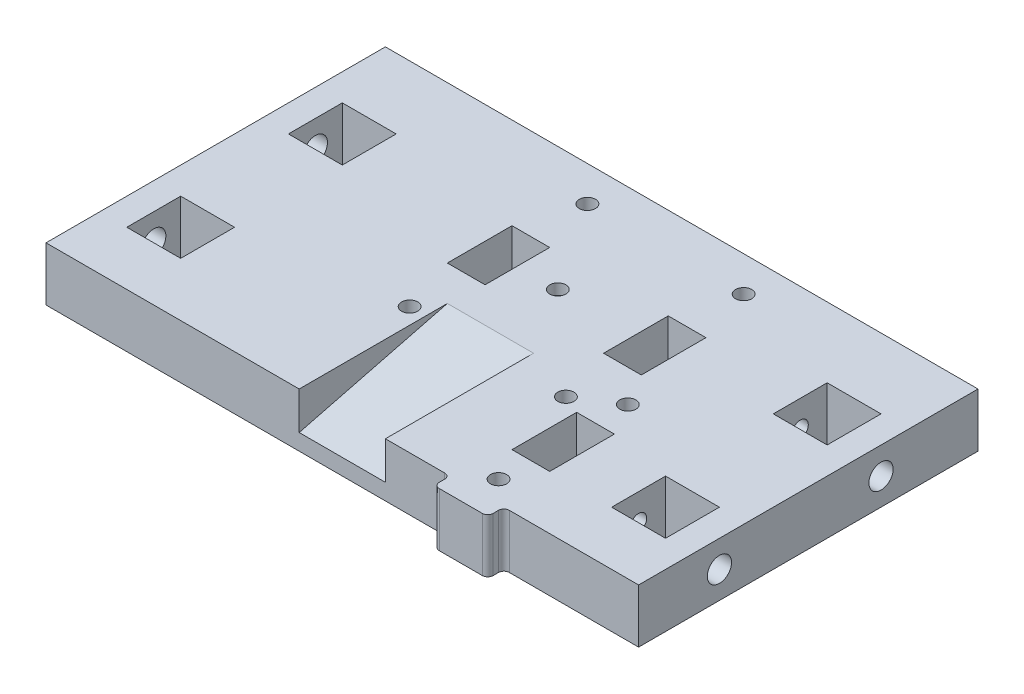
from build123d import *

# Parameters (mm, degrees)
CROQUIS1_W              = 80
CROQUIS1_H              = 60
CROQUIS1_R              = 1.5
CROQUIS1_W_2            = 7
CROQUIS1_H_2            = 25
CROQUIS1_W_3            = 10
CROQUIS1_H_3            = 20
CROQUIS1_H_4            = 10
CROQUIS1_W_4            = 5
CROQUIS1_H_5            = 6.5
SALIENTE_EXTRUIR1_DEPTH = 10
CORTAR_EXTRUIR1_DEPTH   = 5
CROQUIS3_R              = 1.5
CORTAR_EXTRUIR2_DEPTH   = 25
CROQUIS6_R              = 1.5
CORTAR_EXTRUIR3_DEPTH   = 25
CROQUIS8_W              = 15
CROQUIS8_H              = 17.838651154
CROQUIS8_R              = 1.5
SALIENTE_EXTRUIR2_DEPTH = 2
CORTAR_EXTRUIR4_START   = -55
CORTAR_EXTRUIR4_DEPTH   = 8
CROQUIS10_R             = 1.5
CROQUIS10_W             = 7
CROQUIS10_H             = 12
CORTAR_EXTRUIR5_DEPTH   = 16
CROQUIS12_W             = 110
CROQUIS12_H             = 10
SALIENTE_EXTRUIR3_DEPTH = 3
CORTAR_EXTRUIR6_DEPTH   = 5
SALIENTE_EXTRUIR4_DEPTH = 10
CROQUIS15_R             = 2.25
CORTAR_EXTRUIR7_DEPTH   = 10
CROQUIS16_R             = 2.25
CORTAR_EXTRUIR8_DEPTH   = 10


with BuildPart() as part:
    # Croquis1 → Saliente-Extruir1 (new body)
    with BuildSketch(Plane(origin=(0, 0, 0), x_dir=(1, 0, 0), z_dir=(0, 1, 0))):
        with Locations((0, -10)):
            Rectangle(CROQUIS1_W, CROQUIS1_H)
        with Locations(Location((18, -16.5, 0), (0, 0, 270))):
            Circle(CROQUIS1_R, mode=Mode.SUBTRACT)
        with Locations(Location((-11, -16.5, 0), (0, 0, 270))):
            Circle(CROQUIS1_R, mode=Mode.SUBTRACT)
        with Locations(Location((18, 16.5, 0), (0, 0, 270))):
            Circle(CROQUIS1_R, mode=Mode.SUBTRACT)
        with Locations(Location((-11, 16.5, 0), (0, 0, 270))):
            Circle(CROQUIS1_R, mode=Mode.SUBTRACT)
        with Locations((18, 0)):
            Rectangle(CROQUIS1_W_2, CROQUIS1_H_2, mode=Mode.SUBTRACT)
        Polygon((6.495190528, 3.75), (0, 7.5), (-6.495190528, 3.75), (-6.495190528, -3.75), (0, -7.5), (6.495190528, -3.75), align=None, mode=Mode.SUBTRACT)
        with Locations((-11, 0)):
            Rectangle(CROQUIS1_W_2, CROQUIS1_H_2, mode=Mode.SUBTRACT)
        with Locations((-45, -10)):
            Rectangle(CROQUIS1_W_3, CROQUIS1_H_3)
        with Locations((-45, -35)):
            Rectangle(CROQUIS1_W_3, CROQUIS1_H_4)
        with Locations((-52.5, -10)):
            Rectangle(CROQUIS1_W_4, CROQUIS1_H)
        with Locations((-45, 15)):
            Rectangle(CROQUIS1_W_3, CROQUIS1_H_4)
        with Locations((45, 15)):
            Rectangle(CROQUIS1_W_3, CROQUIS1_H_4)
        with Locations((52.5, -10)):
            Rectangle(CROQUIS1_W_4, CROQUIS1_H)
        with Locations((45, -10)):
            Rectangle(CROQUIS1_W_3, CROQUIS1_H_3)
        with Locations((45, -35)):
            Rectangle(CROQUIS1_W_3, CROQUIS1_H_4)
        with Locations((-11, 9.25)):
            Rectangle(CROQUIS1_W_2, CROQUIS1_H_5)
        with Locations((-11, -9.25)):
            Rectangle(CROQUIS1_W_2, CROQUIS1_H_5)
        with Locations((18, 9.25)):
            Rectangle(CROQUIS1_W_2, CROQUIS1_H_5)
        with Locations((18, -9.25)):
            Rectangle(CROQUIS1_W_2, CROQUIS1_H_5)
    extrude(amount=SALIENTE_EXTRUIR1_DEPTH)

    # Croquis2 → Cortar-Extruir1 (cut)
    with BuildSketch(Plane.XZ):
        Polygon((-6.958548116, 16.5), (-8.979274058, 20), (-13.020725942, 20), (-15.041451884, 16.5), (-13.020725942, 13), (-8.979274058, 13), align=None)
        Polygon((22.041451884, 16.5), (20.020725942, 20), (15.979274058, 20), (13.958548116, 16.5), (15.979274058, 13), (20.020725942, 13), align=None)
        Polygon((-6.958548116, -16.5), (-8.979274058, -13), (-13.020725942, -13), (-15.041451884, -16.5), (-13.020725942, -20), (-8.979274058, -20), align=None)
        Polygon((22.041451884, -16.5), (20.020725942, -13), (15.979274058, -13), (13.958548116, -16.5), (15.979274058, -20), (20.020725942, -20), align=None)
    extrude(amount=-CORTAR_EXTRUIR1_DEPTH, mode=Mode.SUBTRACT)

    # Croquis3 → Cortar-Extruir2 (cut)
    with BuildSketch(Plane(origin=(55, 0, 0), x_dir=(0, 0, -1), z_dir=(1, 0, 0))):
        with Locations((-25, 5)):
            Circle(CROQUIS3_R)
        with Locations((5, 5)):
            Circle(CROQUIS3_R)
    extrude(amount=-CORTAR_EXTRUIR2_DEPTH, mode=Mode.SUBTRACT)

    # Croquis6 → Cortar-Extruir3 (cut)
    with BuildSketch(Plane.ZY.offset(55)):
        with Locations(Location((-5, 5, 0), (0, 0, 180))):
            Circle(CROQUIS6_R)
        with Locations(Location((25, 5, 0), (0, 0, 180))):
            Circle(CROQUIS6_R)
    extrude(amount=-CORTAR_EXTRUIR3_DEPTH, mode=Mode.SUBTRACT)

    # Croquis8 → Saliente-Extruir2 (add)
    with BuildSketch(Plane(origin=(0, 10, 0), x_dir=(1, 0, 0), z_dir=(0, 1, 0))):
        Rectangle(CROQUIS8_W, CROQUIS8_H)
        with Locations(Location((0, 0, 0), (0, 0, 270))):
            Circle(CROQUIS8_R, mode=Mode.SUBTRACT)
    extrude(amount=-SALIENTE_EXTRUIR2_DEPTH)

    # Croquis9 → Cortar-Extruir4 (cut, symmetric)
    with BuildSketch(Plane(origin=(55, 0, 0), x_dir=(0, 0, -1), z_dir=(1, 0, 0)).offset(CORTAR_EXTRUIR4_START)):
        Polygon((-40, 3), (-12.5, 10), (-40, 10), align=None)
    extrude(amount=CORTAR_EXTRUIR4_DEPTH, both=True, mode=Mode.SUBTRACT)

    # Croquis10 → Cortar-Extruir5 (cut)
    with BuildSketch(Plane(origin=(0, 10, 0), x_dir=(1, 0, 0), z_dir=(0, 1, 0))):
        with Locations(Location((25, -12, 0), (0, 0, 270))):
            Circle(CROQUIS10_R)
        with Locations(Location((25, -36, 0), (0, 0, 270))):
            Circle(CROQUIS10_R)
        with Locations((25, -24)):
            Rectangle(CROQUIS10_W, CROQUIS10_H)
    extrude(amount=-CORTAR_EXTRUIR5_DEPTH, mode=Mode.SUBTRACT)

    # Croquis12 → Saliente-Extruir3 (add)
    with BuildSketch(Plane(origin=(0, 0, -20), x_dir=(-1, 0, 0), z_dir=(0, 0, -1))):
        with Locations((0, 5)):
            Rectangle(CROQUIS12_W, CROQUIS12_H)
    extrude(amount=SALIENTE_EXTRUIR3_DEPTH)

    # Croquis13 → Cortar-Extruir6 (cut)
    with BuildSketch(Plane.XZ):
        Polygon((29.041451884, 12), (27.020725942, 15.5), (22.979274058, 15.5), (20.958548116, 12), (22.979274058, 8.5), (27.020725942, 8.5), align=None)
        Polygon((29.041451884, 36), (27.020725942, 39.5), (22.979274058, 39.5), (20.958548116, 36), (22.979274058, 32.5), (27.020725942, 32.5), align=None)
    extrude(amount=-CORTAR_EXTRUIR6_DEPTH, mode=Mode.SUBTRACT)

    # Croquis14 → Saliente-Extruir4 (add)
    with BuildSketch(Plane.XZ):
        with BuildLine():
            Line((30, 41), (30, 42))
            ThreePointArc((30, 42), (29.707106781, 42.707106781), (29, 43))
            Line((29, 43), (21, 43))
            ThreePointArc((21, 43), (20.292893219, 42.707106781), (20, 42))
            Line((20, 42), (20, 41))
            ThreePointArc((20, 41), (19.707106781, 40.292893219), (19, 40))
            Line((19, 40), (31, 40))
            ThreePointArc((31, 40), (30.292893219, 40.292893219), (30, 41))
        make_face()
    extrude(amount=-SALIENTE_EXTRUIR4_DEPTH)

    # Croquis15 → Cortar-Extruir7 (cut)
    with BuildSketch(Plane(origin=(55, 0, 0), x_dir=(0, 0, -1), z_dir=(1, 0, 0))):
        with Locations((-25, 5)):
            Circle(CROQUIS15_R)
        with Locations((5, 5)):
            Circle(CROQUIS15_R)
    extrude(amount=-CORTAR_EXTRUIR7_DEPTH, mode=Mode.SUBTRACT)

    # Croquis16 → Cortar-Extruir8 (cut)
    with BuildSketch(Plane.ZY.offset(55)):
        with Locations(Location((-5, 5, 0), (0, 0, 180))):
            Circle(CROQUIS16_R)
        with Locations(Location((25, 5, 0), (0, 0, 180))):
            Circle(CROQUIS16_R)
    extrude(amount=-CORTAR_EXTRUIR8_DEPTH, mode=Mode.SUBTRACT)


solid = part.part
